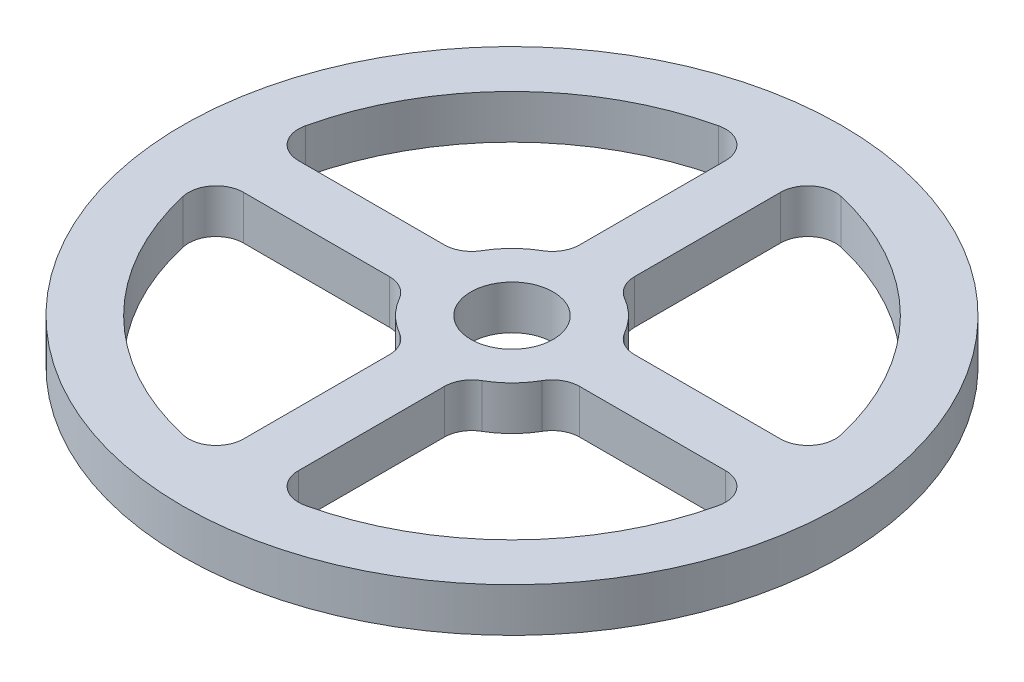
from build123d import *

# Parameters (mm, degrees)
SKETCH1_R           = 120
SKETCH1_R_2         = 15
BOSS_EXTRUDE1_DEPTH = 16


with BuildPart() as part:
    # Sketch1 → Boss-Extrude1 (new body)
    with BuildSketch(Plane(origin=(0, 0, 0), x_dir=(1, 0, 0), z_dir=(0, 1, 0))):
        Circle(SKETCH1_R)
        Circle(SKETCH1_R_2, mode=Mode.SUBTRACT)
        with BuildLine():
            Line((34.641016151, 10), (87.749643874, 10))
            ThreePointArc((87.749643874, 10), (95.567003474, 13.763904355), (97.499604304, 22.222222222))
            ThreePointArc((97.499604304, 22.222222222), (70.710678119, 70.710678119), (22.222222222, 97.499604304))
            ThreePointArc((22.222222222, 97.499604304), (13.763904355, 95.567003474), (10, 87.749643874))
            Line((10, 87.749643874), (10, 34.641016151))
            ThreePointArc((10, 34.641016151), (11.339745962, 29.641016151), (15, 25.980762114))
            ThreePointArc((15, 25.980762114), (21.213203436, 21.213203436), (25.980762114, 15))
            ThreePointArc((25.980762114, 15), (29.641016151, 11.339745962), (34.641016151, 10))
        make_face(mode=Mode.SUBTRACT)
        with BuildLine():
            Line((-10, 34.641016151), (-10, 87.749643874))
            ThreePointArc((-10, 87.749643874), (-13.763904355, 95.567003474), (-22.222222222, 97.499604304))
            ThreePointArc((-22.222222222, 97.499604304), (-70.710678119, 70.710678119), (-97.499604304, 22.222222222))
            ThreePointArc((-97.499604304, 22.222222222), (-95.567003474, 13.763904355), (-87.749643874, 10))
            Line((-87.749643874, 10), (-34.641016151, 10))
            ThreePointArc((-34.641016151, 10), (-29.641016151, 11.339745962), (-25.980762114, 15))
            ThreePointArc((-25.980762114, 15), (-21.213203436, 21.213203436), (-15, 25.980762114))
            ThreePointArc((-15, 25.980762114), (-11.339745962, 29.641016151), (-10, 34.641016151))
        make_face(mode=Mode.SUBTRACT)
        with BuildLine():
            Line((34.641016151, -10), (87.749643874, -10))
            ThreePointArc((87.749643874, -10), (95.567003474, -13.763904355), (97.499604304, -22.222222222))
            ThreePointArc((97.499604304, -22.222222222), (70.710678119, -70.710678119), (22.222222222, -97.499604304))
            ThreePointArc((22.222222222, -97.499604304), (13.763904355, -95.567003474), (10, -87.749643874))
            Line((10, -87.749643874), (10, -34.641016151))
            ThreePointArc((10, -34.641016151), (11.339745962, -29.641016151), (15, -25.980762114))
            ThreePointArc((15, -25.980762114), (21.213203436, -21.213203436), (25.980762114, -15))
            ThreePointArc((25.980762114, -15), (29.641016151, -11.339745962), (34.641016151, -10))
        make_face(mode=Mode.SUBTRACT)
        with BuildLine():
            Line((-10, -34.641016151), (-10, -87.749643874))
            ThreePointArc((-10, -87.749643874), (-13.763904355, -95.567003474), (-22.222222222, -97.499604304))
            ThreePointArc((-22.222222222, -97.499604304), (-70.710678119, -70.710678119), (-97.499604304, -22.222222222))
            ThreePointArc((-97.499604304, -22.222222222), (-95.567003474, -13.763904355), (-87.749643874, -10))
            Line((-87.749643874, -10), (-34.641016151, -10))
            ThreePointArc((-34.641016151, -10), (-29.641016151, -11.339745962), (-25.980762114, -15))
            ThreePointArc((-25.980762114, -15), (-21.213203436, -21.213203436), (-15, -25.980762114))
            ThreePointArc((-15, -25.980762114), (-11.339745962, -29.641016151), (-10, -34.641016151))
        make_face(mode=Mode.SUBTRACT)
    extrude(amount=BOSS_EXTRUDE1_DEPTH)


solid = part.part
